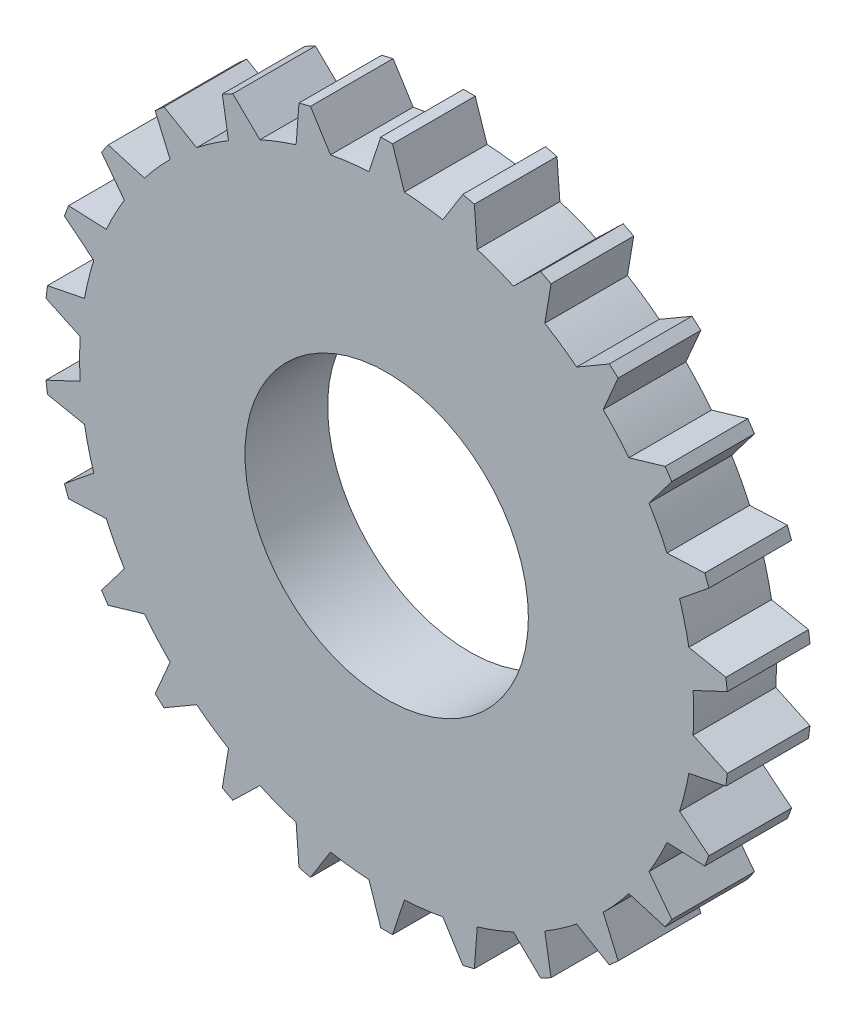
from build123d import *

# Parameters (mm, degrees)
SKETCH1_R           = 12
BOSS_EXTRUDE1_DEPTH = 7


with BuildPart() as part:
    # Sketch1 → Boss-Extrude1 (new body)
    with BuildSketch(Plane.XY):
        with BuildLine():
            Line((6.453651746, 28.272785132), (4.75543091, 25.561413828))
            ThreePointArc((4.75543091, 25.561413828), (3.133953687, 25.810430727), (1.5, 25.956694705))
            Line((1.5, 25.956694705), (0.5, 28.995689335))
            Line((0.5, 28.995689335), (-0.5, 28.995689335))
            Line((-0.5, 28.995689335), (-1.5, 25.956694705))
            ThreePointArc((-1.5, 25.956694705), (-3.133953687, 25.810430727), (-4.75543091, 25.561413828))
            Line((-4.75543091, 25.561413828), (-6.453651746, 28.272785132))
            Line((-6.453651746, 28.272785132), (-7.424593563, 28.033469468))
            Line((-7.424593563, 28.033469468), (-7.668256362, 24.843466835))
            ThreePointArc((-7.668256362, 24.843466835), (-9.219727063, 24.31042231), (-10.734493461, 23.680596491))
            Line((-10.734493461, 23.680596491), (-13.03224071, 25.906769425))
            Line((-13.03224071, 25.906769425), (-13.917696736, 25.442046253))
            Line((-13.917696736, 25.442046253), (-13.390861537, 22.286426974))
            ThreePointArc((-13.390861537, 22.286426974), (-14.769683415, 21.397580513), (-16.08970627, 20.423548961))
            Line((-16.08970627, 20.423548961), (-18.853443215, 22.035146447))
            Line((-18.853443215, 22.035146447), (-19.601953963, 21.372023789))
            Line((-19.601953963, 21.372023789), (-18.335238514, 18.434180986))
            ThreePointArc((-18.335238514, 18.434180986), (-19.461279452, 17.241189114), (-20.509843834, 15.979559002))
            Line((-20.509843834, 15.979559002), (-23.57895213, 16.882920851))
            Line((-23.57895213, 16.882920851), (-24.147016876, 16.059936985))
            Line((-24.147016876, 16.059936985), (-22.214038074, 13.510607405))
            ThreePointArc((-22.214038074, 13.510607405), (-23.021856667, 12.082802473), (-23.738023825, 10.606895158))
            Line((-23.738023825, 10.606895158), (-26.934138052, 10.749521263))
            Line((-26.934138052, 10.749521263), (-27.288742939, 9.81450502))
            Line((-27.288742939, 9.81450502), (-24.801838486, 7.80184643))
            ThreePointArc((-24.801838486, 7.80184643), (-25.244487253, 6.222207271), (-25.586636155, 4.617797121))
            Line((-25.586636155, 4.617797121), (-28.724009773, 3.991398571))
            Line((-28.724009773, 3.991398571), (-28.844546453, 2.998689697))
            Line((-28.844546453, 2.998689697), (-25.948246196, 1.639670499))
            ThreePointArc((-25.948246196, 1.639670499), (-26, 0), (-25.948246196, -1.639670499))
            Line((-25.948246196, -1.639670499), (-28.844546453, -2.998689697))
            Line((-28.844546453, -2.998689697), (-28.724009773, -3.991398571))
            Line((-28.724009773, -3.991398571), (-25.586636155, -4.617797121))
            ThreePointArc((-25.586636155, -4.617797121), (-25.244487253, -6.222207271), (-24.801838486, -7.80184643))
            Line((-24.801838486, -7.80184643), (-27.288742939, -9.81450502))
            Line((-27.288742939, -9.81450502), (-26.934138052, -10.749521263))
            Line((-26.934138052, -10.749521263), (-23.738023825, -10.606895158))
            ThreePointArc((-23.738023825, -10.606895158), (-23.021856667, -12.082802473), (-22.214038074, -13.510607405))
            Line((-22.214038074, -13.510607405), (-24.147016876, -16.059936985))
            Line((-24.147016876, -16.059936985), (-23.57895213, -16.882920851))
            Line((-23.57895213, -16.882920851), (-20.509843834, -15.979559002))
            ThreePointArc((-20.509843834, -15.979559002), (-19.461279452, -17.241189114), (-18.335238514, -18.434180986))
            Line((-18.335238514, -18.434180986), (-19.601953963, -21.372023789))
            Line((-19.601953963, -21.372023789), (-18.853443215, -22.035146447))
            Line((-18.853443215, -22.035146447), (-16.08970627, -20.423548961))
            ThreePointArc((-16.08970627, -20.423548961), (-14.769683415, -21.397580513), (-13.390861537, -22.286426974))
            Line((-13.390861537, -22.286426974), (-13.917696736, -25.442046253))
            Line((-13.917696736, -25.442046253), (-13.03224071, -25.906769425))
            Line((-13.03224071, -25.906769425), (-10.734493461, -23.680596491))
            ThreePointArc((-10.734493461, -23.680596491), (-9.219727063, -24.31042231), (-7.668256362, -24.843466835))
            Line((-7.668256362, -24.843466835), (-7.424593563, -28.033469468))
            Line((-7.424593563, -28.033469468), (-6.453651746, -28.272785132))
            Line((-6.453651746, -28.272785132), (-4.75543091, -25.561413828))
            ThreePointArc((-4.75543091, -25.561413828), (-3.133953687, -25.810430727), (-1.5, -25.956694705))
            Line((-1.5, -25.956694705), (-0.5, -28.995689335))
            Line((-0.5, -28.995689335), (0.5, -28.995689335))
            Line((0.5, -28.995689335), (1.5, -25.956694705))
            ThreePointArc((1.5, -25.956694705), (3.133953687, -25.810430727), (4.75543091, -25.561413828))
            Line((4.75543091, -25.561413828), (6.453651746, -28.272785132))
            Line((6.453651746, -28.272785132), (7.424593563, -28.033469468))
            Line((7.424593563, -28.033469468), (7.668256362, -24.843466835))
            ThreePointArc((7.668256362, -24.843466835), (9.219727063, -24.31042231), (10.734493461, -23.680596491))
            Line((10.734493461, -23.680596491), (13.03224071, -25.906769425))
            Line((13.03224071, -25.906769425), (13.917696736, -25.442046253))
            Line((13.917696736, -25.442046253), (13.390861537, -22.286426974))
            ThreePointArc((13.390861537, -22.286426974), (14.769683415, -21.397580513), (16.08970627, -20.423548961))
            Line((16.08970627, -20.423548961), (18.853443215, -22.035146447))
            Line((18.853443215, -22.035146447), (19.601953963, -21.372023789))
            Line((19.601953963, -21.372023789), (18.335238514, -18.434180986))
            ThreePointArc((18.335238514, -18.434180986), (19.461279452, -17.241189114), (20.509843834, -15.979559002))
            Line((20.509843834, -15.979559002), (23.57895213, -16.882920851))
            Line((23.57895213, -16.882920851), (24.147016876, -16.059936985))
            Line((24.147016876, -16.059936985), (22.214038074, -13.510607405))
            ThreePointArc((22.214038074, -13.510607405), (23.021856667, -12.082802473), (23.738023825, -10.606895158))
            Line((23.738023825, -10.606895158), (26.934138052, -10.749521263))
            Line((26.934138052, -10.749521263), (27.288742939, -9.81450502))
            Line((27.288742939, -9.81450502), (24.801838486, -7.80184643))
            ThreePointArc((24.801838486, -7.80184643), (25.244487253, -6.222207271), (25.586636155, -4.617797121))
            Line((25.586636155, -4.617797121), (28.724009773, -3.991398571))
            Line((28.724009773, -3.991398571), (28.844546453, -2.998689697))
            Line((28.844546453, -2.998689697), (25.948246196, -1.639670499))
            ThreePointArc((25.948246196, -1.639670499), (26, 0), (25.948246196, 1.639670499))
            Line((25.948246196, 1.639670499), (28.844546453, 2.998689697))
            Line((28.844546453, 2.998689697), (28.724009773, 3.991398571))
            Line((28.724009773, 3.991398571), (25.586636155, 4.617797121))
            ThreePointArc((25.586636155, 4.617797121), (25.244487253, 6.222207271), (24.801838486, 7.80184643))
            Line((24.801838486, 7.80184643), (27.288742939, 9.81450502))
            Line((27.288742939, 9.81450502), (26.934138052, 10.749521263))
            Line((26.934138052, 10.749521263), (23.738023825, 10.606895158))
            ThreePointArc((23.738023825, 10.606895158), (23.021856667, 12.082802473), (22.214038074, 13.510607405))
            Line((22.214038074, 13.510607405), (24.147016876, 16.059936985))
            Line((24.147016876, 16.059936985), (23.57895213, 16.882920851))
            Line((23.57895213, 16.882920851), (20.509843834, 15.979559002))
            ThreePointArc((20.509843834, 15.979559002), (19.461279452, 17.241189114), (18.335238514, 18.434180986))
            Line((18.335238514, 18.434180986), (19.601953963, 21.372023789))
            Line((19.601953963, 21.372023789), (18.853443215, 22.035146447))
            Line((18.853443215, 22.035146447), (16.08970627, 20.423548961))
            ThreePointArc((16.08970627, 20.423548961), (14.769683415, 21.397580513), (13.390861537, 22.286426974))
            Line((13.390861537, 22.286426974), (13.917696736, 25.442046253))
            Line((13.917696736, 25.442046253), (13.03224071, 25.906769425))
            Line((13.03224071, 25.906769425), (10.734493461, 23.680596491))
            ThreePointArc((10.734493461, 23.680596491), (9.219727063, 24.31042231), (7.668256362, 24.843466835))
            Line((7.668256362, 24.843466835), (7.424593563, 28.033469468))
            Line((7.424593563, 28.033469468), (6.453651746, 28.272785132))
        make_face()
        Circle(SKETCH1_R, mode=Mode.SUBTRACT)
    extrude(amount=BOSS_EXTRUDE1_DEPTH)


solid = part.part
